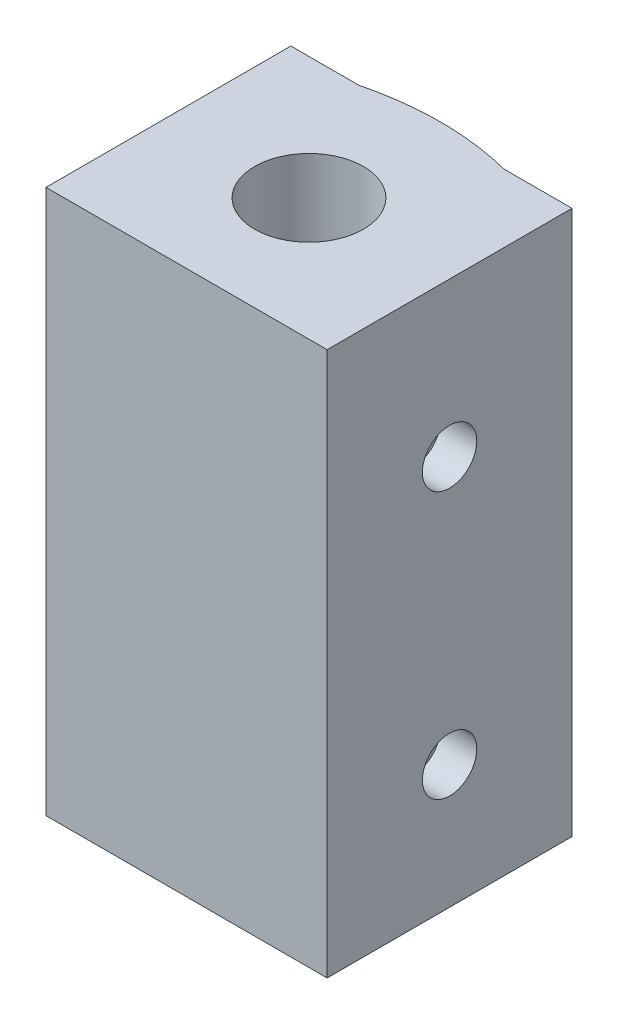
from build123d import *

# Parameters (mm, degrees)
BOSS_EXTRUDE1_DEPTH = 30
SKETCH2_R           = 3
CUT_EXTRUDE1_DEPTH  = 18
SKETCH3_R           = 1.75
CUT_EXTRUDE2_DEPTH  = 13
SKETCH4_R           = 1.5
CUT_EXTRUDE3_DEPTH  = 2


with BuildPart() as part:
    # Sketch1 → Boss-Extrude1 (new body)
    with BuildSketch(Plane(origin=(0, 0, 0), x_dir=(1, 0, 0), z_dir=(0, 1, 0))):
        with BuildLine():
            Line((0, 0), (15.5, 0))
            Line((15.5, 0), (15.5, 13.5))
            Line((15.5, 13.5), (11.75, 13.5))
            ThreePointArc((11.75, 13.5), (7.75, 14), (3.75, 13.5))
            Line((3.75, 13.5), (0, 13.5))
            Line((0, 13.5), (0, 0))
        make_face()
    extrude(amount=BOSS_EXTRUDE1_DEPTH)

    # Sketch2 → Cut-Extrude1 (cut)
    with BuildSketch(Plane(origin=(0, 30, 0), x_dir=(1, 0, 0), z_dir=(0, 1, 0))):
        with Locations((7.75, 6.75)):
            Circle(SKETCH2_R)
    extrude(amount=-CUT_EXTRUDE1_DEPTH, mode=Mode.SUBTRACT)

    # Sketch3 → Cut-Extrude2 (cut, through all)
    with BuildSketch(Plane(origin=(0, 12, 0), x_dir=(1, 0, 0), z_dir=(0, 1, 0))):
        with Locations((7.75, 6.75)):
            Circle(SKETCH3_R)
    extrude(amount=-CUT_EXTRUDE2_DEPTH, mode=Mode.SUBTRACT)

    # Sketch4 → Cut-Extrude3 (cut)
    with BuildSketch(Plane(origin=(15.5, 0, 0), x_dir=(0, 0, -1), z_dir=(1, 0, 0))):
        with Locations((6.75, 21.515)):
            Circle(SKETCH4_R)
        with Locations((6.75, 6.815)):
            Circle(SKETCH4_R)
    extrude(amount=-CUT_EXTRUDE3_DEPTH, mode=Mode.SUBTRACT)


solid = part.part
